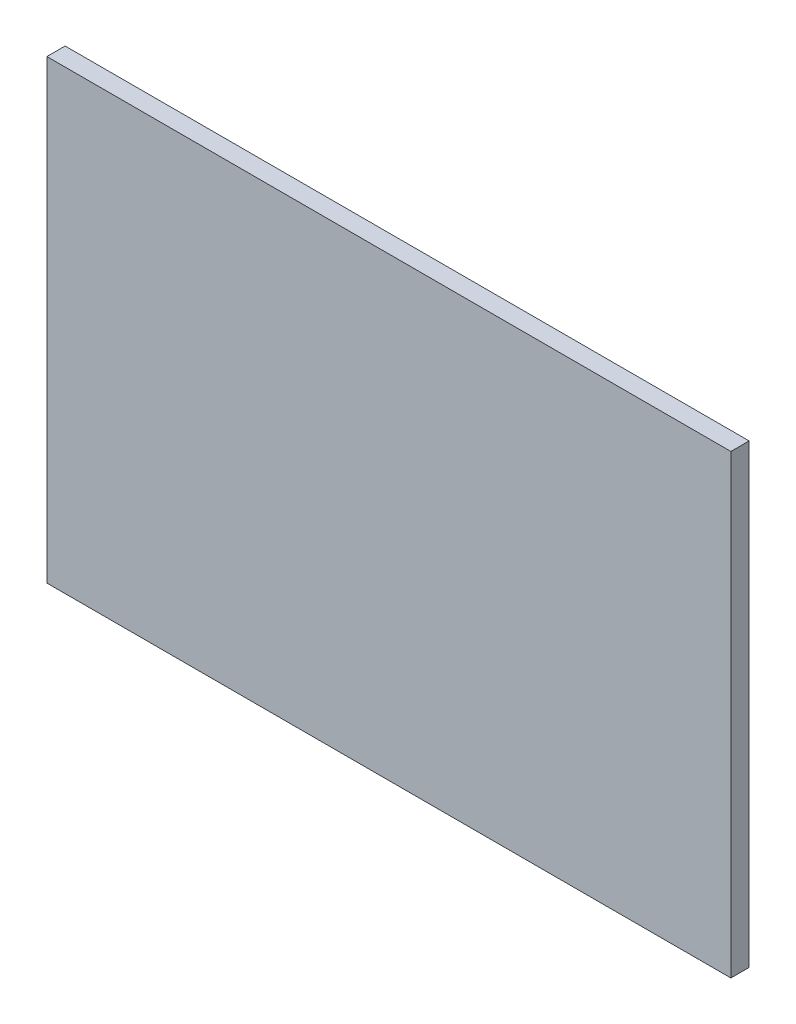
from build123d import *

# Parameters (mm, degrees)
SKETCH1_W           = 150
SKETCH1_H           = 4
BOSS_EXTRUDE1_DEPTH = 100


with BuildPart() as part:
    # Sketch1 → Boss-Extrude1 (new body)
    with BuildSketch(Plane(origin=(0, 0, 0), x_dir=(1, 0, 0), z_dir=(0, 1, 0))):
        with Locations((0, -23)):
            Rectangle(SKETCH1_W, SKETCH1_H)
    extrude(amount=BOSS_EXTRUDE1_DEPTH)


solid = part.part
